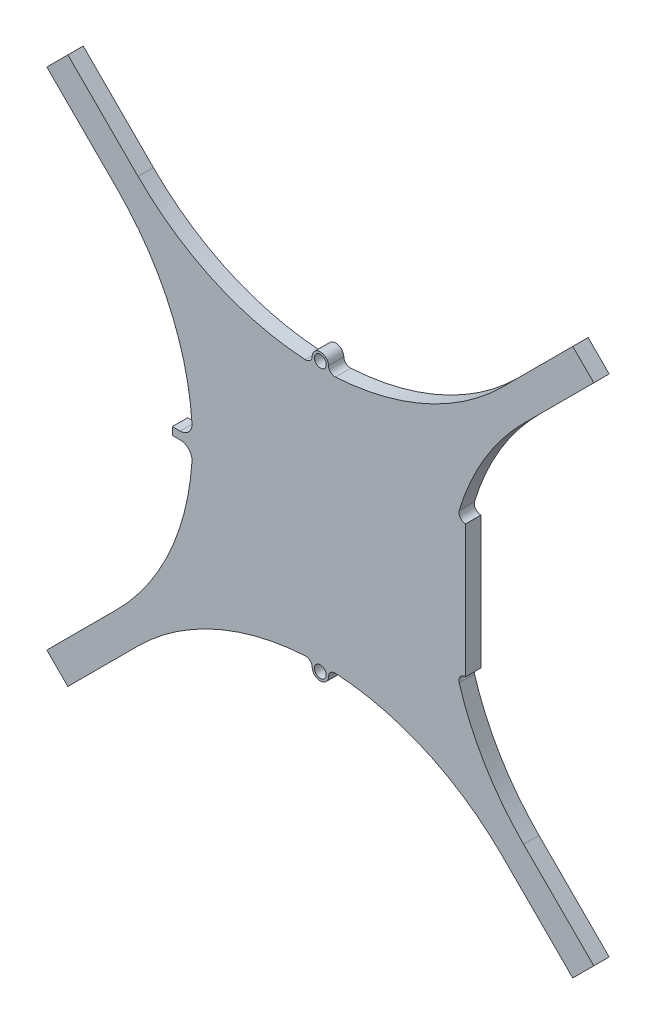
from build123d import *

# Parameters (mm, degrees)
SKETCH1_R           = 0.634780864
BOSS_EXTRUDE1_DEPTH = 1.65
FILLET1_R           = 0.7112
FILLET2_R           = 0.7112
FILLET3_R           = 1.27


with BuildPart() as part:
    # Sketch1 → Boss-Extrude1 (new body)
    with BuildSketch(Plane.XY):
        with BuildLine():
            Line((-27.135222714, 29.397964527), (-29.397964527, 27.135222714))
            Line((-29.397964527, 27.135222714), (-21.855060774, 19.592318961))
            ThreePointArc((-21.855060774, 19.592318961), (-15.928204538, 10.7930358), (-13.742710724, 0.41138729))
            Line((-13.742710724, 0.41138729), (-15.908512943, 0.41138729))
            Line((-15.908512943, 0.41138729), (-15.908512943, -0.41138729))
            Line((-15.908512943, -0.41138729), (-13.742710724, -0.41138729))
            ThreePointArc((-13.742710724, -0.41138729), (-15.928204538, -10.7930358), (-21.855060774, -19.592318961))
            Line((-21.855060774, -19.592318961), (-29.397964527, -27.135222714))
            Line((-29.397964527, -27.135222714), (-27.135222714, -29.397964527))
            Line((-27.135222714, -29.397964527), (-19.592318961, -21.855060774))
            ThreePointArc((-19.592318961, -21.855060774), (-10.842511416, -15.949186255), (-0.51885361, -13.744514983))
            ThreePointArc((-0.51885361, -13.744514983), (0, -15.324082887), (0.51885361, -13.744514983))
            ThreePointArc((0.51885361, -13.744514983), (10.842511416, -15.949186255), (19.592318961, -21.855060774))
            Line((19.592318961, -21.855060774), (27.135222714, -29.397964527))
            Line((27.135222714, -29.397964527), (29.397964527, -27.135222714))
            Line((29.397964527, -27.135222714), (21.855060774, -19.592318961))
            ThreePointArc((21.855060774, -19.592318961), (17.437236913, -13.828628501), (14.668755804, -7.114999994))
            Line((14.668755804, -7.114999994), (15.618947426, -7.114999994))
            Line((15.618947426, -7.114999994), (15.618947426, 7.114999994))
            Line((15.618947426, 7.114999994), (14.668755804, 7.114999994))
            ThreePointArc((14.668755804, 7.114999994), (17.437236913, 13.828628501), (21.855060774, 19.592318961))
            Line((21.855060774, 19.592318961), (29.397964527, 27.135222714))
            Line((29.397964527, 27.135222714), (27.135222714, 29.397964527))
            Line((27.135222714, 29.397964527), (19.592318961, 21.855060774))
            ThreePointArc((19.592318961, 21.855060774), (10.842511416, 15.949186255), (0.51885361, 13.744514983))
            ThreePointArc((0.51885361, 13.744514983), (0, 15.324082887), (-0.51885361, 13.744514983))
            ThreePointArc((-0.51885361, 13.744514983), (-10.842511416, 15.949186255), (-19.592318961, 21.855060774))
            Line((-19.592318961, 21.855060774), (-27.135222714, 29.397964527))
        make_face()
        with Locations((0, 14.449082887)):
            Circle(SKETCH1_R, mode=Mode.SUBTRACT)
        with Locations((0, -14.449082887)):
            Circle(SKETCH1_R, mode=Mode.SUBTRACT)
    extrude(amount=BOSS_EXTRUDE1_DEPTH)

    # Fillet1
    fillet1_edges = [part.edges().sort_by_distance(p)[0] for p in [
        (0.51885361, 13.744514983, 0.825),
        (0.51885361, -13.744514983, 0.825),
        (-0.51885361, -13.744514983, 0.825),
        (-0.51885361, 13.744514983, 0.825),
    ]]
    fillet(fillet1_edges, radius=FILLET1_R)

    # Fillet2
    fillet2_edges = [part.edges().sort_by_distance(p)[0] for p in [
        (14.668755804, 7.114999994, 0.825),
        (14.668755804, -7.114999994, 0.825),
    ]]
    fillet(fillet2_edges, radius=FILLET2_R)

    # Fillet3
    fillet3_edges = [part.edges().sort_by_distance(p)[0] for p in [
        (-13.742710724, -0.41138729, 0.825),
        (-13.742710724, 0.41138729, 0.825),
    ]]
    fillet(fillet3_edges, radius=FILLET3_R)


solid = part.part
